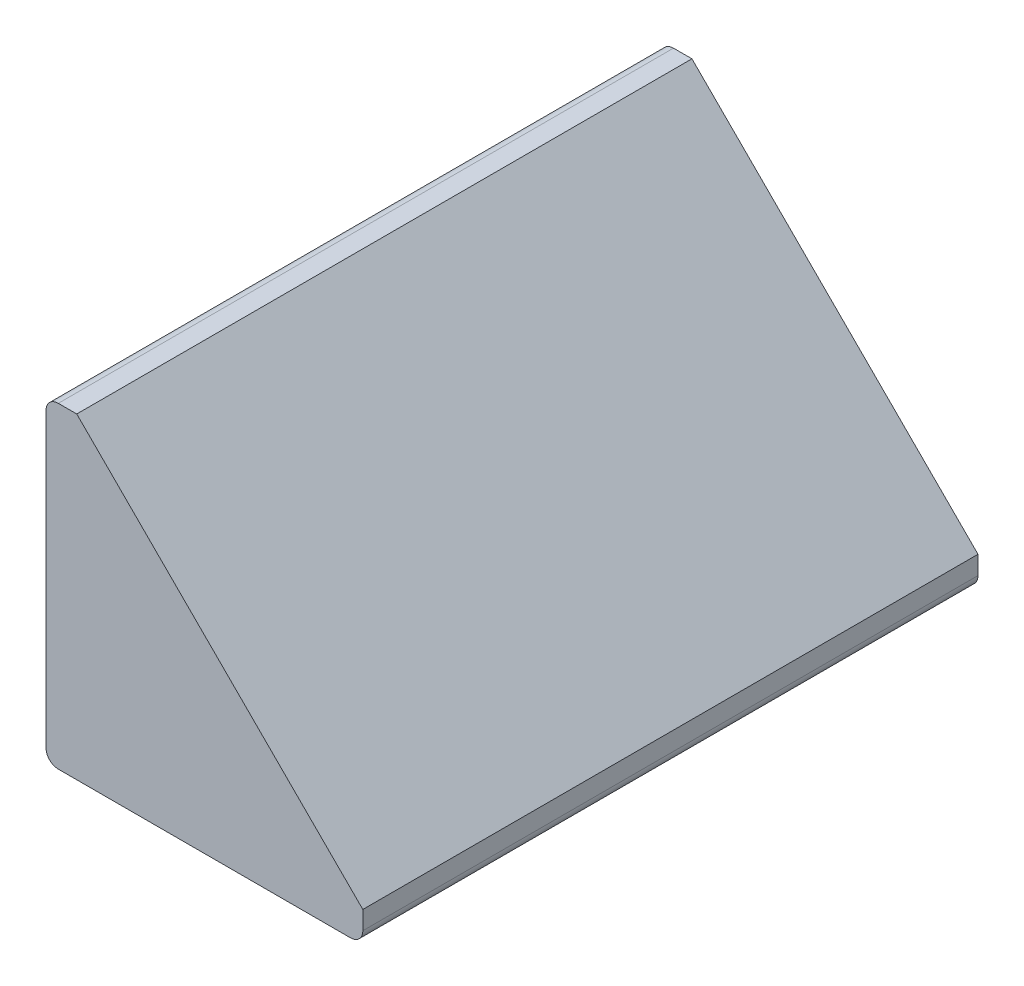
from build123d import *

# Parameters (mm, degrees)
EXTRUDE1_DEPTH = 12.7
FILLET1_R      = 0.508


with BuildPart() as part:
    # Sketch1 → Extrude1 (new body, symmetric)
    with BuildSketch(Plane.XY):
        Polygon((0, 13.081), (0, 0), (13.081, 0), (13.081, 1.27), (1.27, 13.081), align=None)
    extrude(amount=EXTRUDE1_DEPTH, both=True)

    # Fillet1
    fillet1_edges = [part.edges().sort_by_distance(p)[0] for p in [
        (13.081, 0, 0),
        (0, 0, 0),
        (0, 13.081, 0),
    ]]
    fillet(fillet1_edges, radius=FILLET1_R)


solid = part.part
